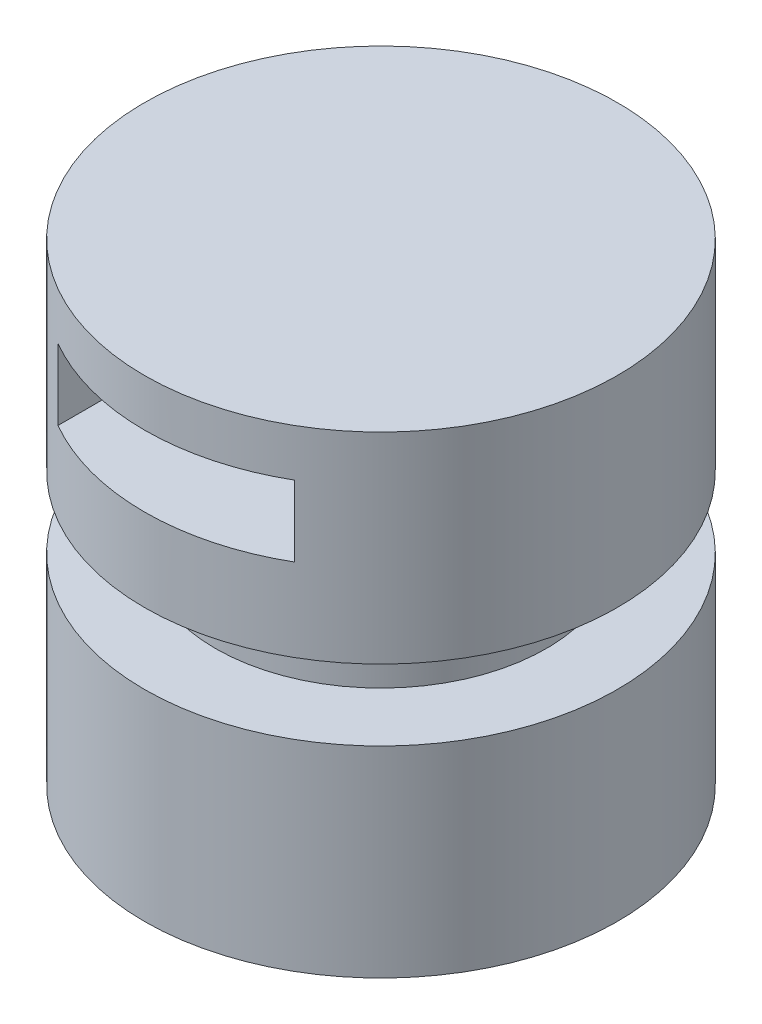
from build123d import *

# Parameters (mm, degrees)
SKETCH2_R               = 100
BOSS_EXTRUDE1_DEPTH     = 200
CUT_EXTRUDE1_DEPTH      = 200
CUT_EXTRUDE1_DEPTH_BACK = 200


with BuildPart() as part:
    # Sketch2 → Boss-Extrude1 (new body)
    with BuildSketch(Plane(origin=(0, 0, 0), x_dir=(1, 0, 0), z_dir=(0, 1, 0))):
        Circle(SKETCH2_R)
    extrude(amount=BOSS_EXTRUDE1_DEPTH)

    # Sketch3 → Cut-Revolve3 (revolve, cut)
    with BuildSketch(Plane.XY):
        Polygon((100, 85), (100, 100), (100, 115), (70, 115), (70, 85), align=None)
    revolve(axis=Axis((0, 235.170477907, 0), (0, -1, 0)), mode=Mode.SUBTRACT)

    # Sketch4 → Cut-Extrude1 (cut, two sides: drawn at the far end of the back side and taken through both)
    with BuildSketch(Plane.XY.offset(-CUT_EXTRUDE1_DEPTH_BACK)):
        Polygon((0, 180), (50, 180), (50, 150), (-50, 150), (-50, 180), align=None)
    extrude(amount=CUT_EXTRUDE1_DEPTH + CUT_EXTRUDE1_DEPTH_BACK, mode=Mode.SUBTRACT)


solid = part.part
